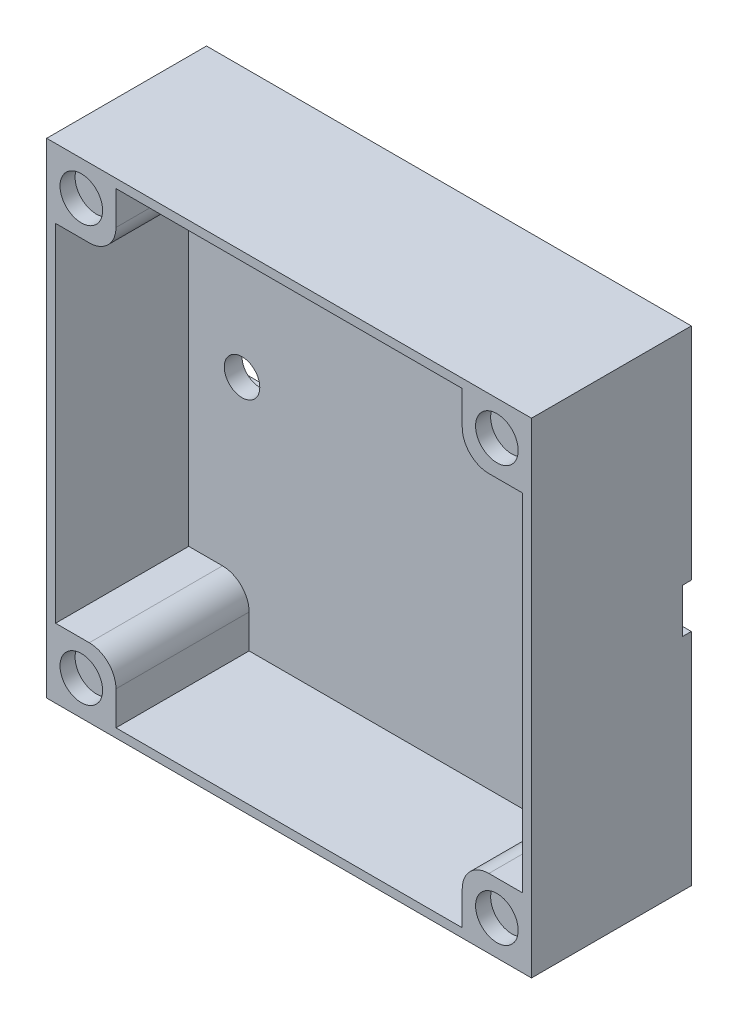
from build123d import *

# Parameters (mm, degrees)
SKICA1_W                 = 54.6
SKICA1_H                 = 54.6
P_IDAT_VYSUNUT_M2_DEPTH  = 3
SKICA5_W                 = 54.6
SKICA5_H                 = 5
ODEBRAT_VYSUNUT_M3_DEPTH = 1
SKICA14_W                = 52.6
SKICA14_H                = 1
P_IDAT_VYSUNUT_M9_DEPTH  = 15
SKICA17_R                = 2
ODEBRAT_VYSUNUT_M8_DEPTH = 4
SKICA19_W                = 7.8
SKICA19_H                = 7.8
P_IDAT_VYSUNUT_M10_DEPTH = 18
SKICA20_R                = 2.4
ODEBRAT_VYSUNUT_M9_DEPTH = 1.7
ZAOBLIT1_R               = 3


with BuildPart() as part:
    # Skica1 → Přidat vysunutím2 (new body)
    with BuildSketch(Plane.XY):
        Rectangle(SKICA1_W, SKICA1_H)
    extrude(amount=P_IDAT_VYSUNUT_M2_DEPTH)

    # Skica5 → Odebrat vysunutím3 (cut)
    with BuildSketch(Plane(origin=(0, 0, 0), x_dir=(-1, 0, 0), z_dir=(0, 0, -1))):
        Rectangle(SKICA5_W, SKICA5_H)
    extrude(amount=-ODEBRAT_VYSUNUT_M3_DEPTH, mode=Mode.SUBTRACT)

    # Skica14 → Přidat vysunutím9 (add)
    with BuildSketch(Plane.XY.offset(3)):
        Polygon((27.3, 27.3), (-27.3, 27.3), (-27.3, -27.3), (-26.3, -27.3), (-26.3, -26.3), (-26.3, 26.3), (26.3, 26.3), (26.3, -26.3), (26.3, -27.3), (27.3, -27.3), align=None)
        with Locations((0, -26.8)):
            Rectangle(SKICA14_W, SKICA14_H)
    extrude(amount=P_IDAT_VYSUNUT_M9_DEPTH)

    # Skica17 → Odebrat vysunutím8 (cut)
    with BuildSketch(Plane(origin=(0, 0, 1), x_dir=(-1, 0, 0), z_dir=(0, 0, -1))):
        with Locations((-20.3, 0)):
            Circle(SKICA17_R)
        with Locations((20.3, 0)):
            Circle(SKICA17_R)
    extrude(amount=-ODEBRAT_VYSUNUT_M8_DEPTH, mode=Mode.SUBTRACT)

    # Skica19 → Přidat vysunutím10 (add)
    with BuildSketch(Plane(origin=(0, 0, 0), x_dir=(-1, 0, 0), z_dir=(0, 0, -1))):
        with Locations((-23.4, 23.4)):
            Rectangle(SKICA19_W, SKICA19_H)
        with Locations((23.4, 23.4)):
            Rectangle(SKICA19_W, SKICA19_H)
        with Locations((-23.4, -23.4)):
            Rectangle(SKICA19_W, SKICA19_H)
        with Locations((23.4, -23.4)):
            Rectangle(SKICA19_W, SKICA19_H)
    extrude(amount=-P_IDAT_VYSUNUT_M10_DEPTH)

    # Skica20 → Odebrat vysunutím9 (cut)
    with BuildSketch(Plane.XY.offset(18)):
        with Locations((-23.4, -23.4)):
            Circle(SKICA20_R)
        with Locations((-23.4, 23.4)):
            Circle(SKICA20_R)
        with Locations((23.400280565, 23.4)):
            Circle(SKICA20_R)
        with Locations((23.400280565, -23.4)):
            Circle(SKICA20_R)
    extrude(amount=-ODEBRAT_VYSUNUT_M9_DEPTH, mode=Mode.SUBTRACT)

    # Zaoblit1
    zaoblit1_edges = [part.edges().sort_by_distance(p)[0] for p in [
        (19.5, -19.5, 10.5),
        (-19.5, -19.5, 10.5),
        (19.5, 19.5, 10.5),
        (-19.5, 19.5, 10.5),
    ]]
    fillet(zaoblit1_edges, radius=ZAOBLIT1_R)


solid = part.part
